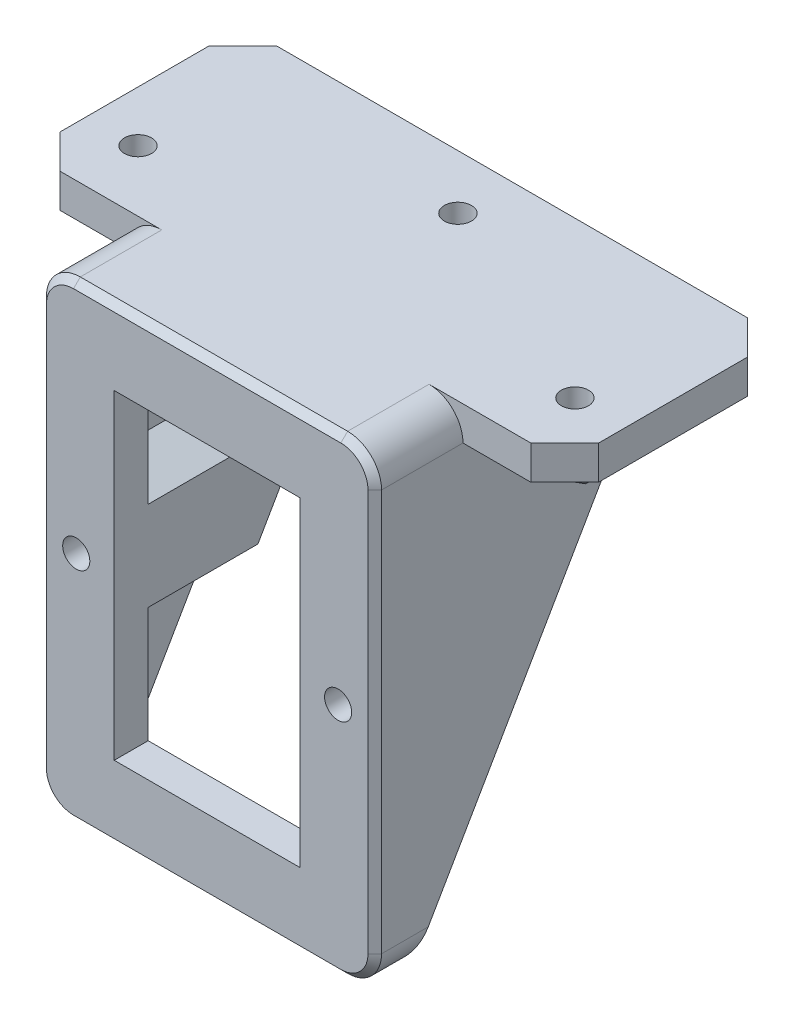
from build123d import *

# Parameters (mm, degrees)
SKETCH1_W           = 49.4
SKETCH1_H           = 69.2
SKETCH1_W_2         = 27.4
SKETCH1_H_2         = 47.2
BOSS_EXTRUDE1_DEPTH = 5
SKETCH2_R           = 2
CUT_EXTRUDE1_DEPTH  = 15
BOSS_EXTRUDE2_DEPTH = 49.4
CUT_EXTRUDE2_DEPTH  = 40.952638628
SKETCH5_W           = 27.4
SKETCH5_H           = 47.2
CUT_EXTRUDE3_DEPTH  = 93
CUT_EXTRUDE4_START  = -5
CUT_EXTRUDE4_DEPTH  = 93
SKETCH7_W           = 79.4
SKETCH7_H           = 44.952638628
BOSS_EXTRUDE3_DEPTH = 5
BOSS_EXTRUDE4_DEPTH = 3
CUT_EXTRUDE5_DEPTH  = 1
SKETCH10_R          = 2
CUT_EXTRUDE6_DEPTH  = 5
SKETCH11_W          = 15
SKETCH11_H          = 5
CUT_EXTRUDE7_DEPTH  = 13
CHAMFER1_SIZE       = 2.75
BOSS_EXTRUDE5_DEPTH = 0.5
CHAMFER2_SIZE       = 0.25
FILLET1_R           = 5
CHAMFER3_SIZE       = 1
CHAMFER4_SIZE       = 5


with BuildPart() as part:
    # Sketch1 → Boss-Extrude1 (new body)
    with BuildSketch(Plane.XY):
        Rectangle(SKETCH1_W, SKETCH1_H)
        Rectangle(SKETCH1_W_2, SKETCH1_H_2, mode=Mode.SUBTRACT)
    extrude(amount=-BOSS_EXTRUDE1_DEPTH)

    # Sketch2 → Cut-Extrude1 (cut)
    with BuildSketch(Plane.XY):
        with Locations((19.3, 0)):
            Circle(SKETCH2_R)
        with Locations((-19.3, 0)):
            Circle(SKETCH2_R)
    extrude(amount=-CUT_EXTRUDE1_DEPTH, mode=Mode.SUBTRACT)

    # Sketch4 → Boss-Extrude2 (add)
    with BuildSketch(Plane(origin=(24.7, 0, 0), x_dir=(0, 0, -1), z_dir=(1, 0, 0))):
        Polygon((5, 34.6), (44.952638628, 34.6), (5, -34.6), align=None)
    extrude(amount=-BOSS_EXTRUDE2_DEPTH)

    # Sketch3 → Cut-Extrude2 (cut, through all)
    with BuildSketch(Plane(origin=(0, 0, -5), x_dir=(-1, 0, 0), z_dir=(0, 0, -1))):
        Polygon((-19.3, -4.041451884), (-15.8, -2.020725942), (-15.8, 2.020725942), (-19.3, 4.041451884), (-22.8, 2.020725942), (-22.8, -2.020725942), align=None)
        Polygon((19.3, -4.041451884), (22.8, -2.020725942), (22.8, 2.020725942), (19.3, 4.041451884), (15.8, 2.020725942), (15.8, -2.020725942), align=None)
    extrude(amount=CUT_EXTRUDE2_DEPTH, mode=Mode.SUBTRACT)

    # Sketch5 → Cut-Extrude3 (cut)
    with BuildSketch(Plane.XY.offset(-5)):
        Rectangle(SKETCH5_W, SKETCH5_H)
    extrude(amount=-CUT_EXTRUDE3_DEPTH, mode=Mode.SUBTRACT)

    # Sketch6 → Cut-Extrude4 (cut)
    with BuildSketch(Plane.XY.offset(CUT_EXTRUDE4_START)):
        Polygon((19.7, 29.6), (-19.7, 29.6), (-19.7, 10.045894684), (-10.8, 4.907477288), (-10.8, -4.907477288), (-19.7, -10.045894684), (-19.7, -34.6), (19.7, -34.6), (19.7, -10.045894684), (10.8, -4.907477288), (10.8, 4.907477288), (19.7, 10.045894684), align=None)
    extrude(amount=-CUT_EXTRUDE4_DEPTH, mode=Mode.SUBTRACT)

    # Sketch7 → Boss-Extrude3 (add)
    with BuildSketch(Plane(origin=(0, 34.6, 0), x_dir=(1, 0, 0), z_dir=(0, 1, 0))):
        with Locations((0, 22.476319314)):
            Rectangle(SKETCH7_W, SKETCH7_H)
    extrude(amount=-BOSS_EXTRUDE3_DEPTH)

    # Sketch8 → Boss-Extrude4 (add)
    with BuildSketch(Plane.XZ.offset(-29.6)):
        Polygon((25.7, -25.75277675), (32.2, -29.505553499), (38.7, -25.75277675), (38.7, -18.24722325), (32.2, -14.494446501), (25.7, -18.24722325), align=None)
        Polygon((32.2, -17.958548116), (28.7, -19.979274058), (28.7, -24.020725942), (32.2, -26.041451884), (35.7, -24.020725942), (35.7, -19.979274058), align=None, mode=Mode.SUBTRACT)
        Polygon((-32.2, -14.494446501), (-38.7, -18.24722325), (-38.7, -25.75277675), (-32.2, -29.505553499), (-25.7, -25.75277675), (-25.7, -18.24722325), align=None)
        Polygon((-32.2, -17.958548116), (-35.7, -19.979274058), (-35.7, -24.020725942), (-32.2, -26.041451884), (-28.7, -24.020725942), (-28.7, -19.979274058), align=None, mode=Mode.SUBTRACT)
        Polygon((0, -29.447085128), (-6.5, -33.199861878), (-6.5, -40.705415378), (0, -44.458192127), (6.5, -40.705415378), (6.5, -33.199861878), align=None)
        Polygon((-3.5, -34.931912686), (-3.5, -38.97336457), (0, -40.994090512), (3.5, -38.97336457), (3.5, -34.931912686), (0, -32.911186744), align=None, mode=Mode.SUBTRACT)
    extrude(amount=BOSS_EXTRUDE4_DEPTH)

    # Sketch9 → Cut-Extrude5 (cut)
    with BuildSketch(Plane.XZ.offset(-29.6)):
        Polygon((35.7, -24.020725942), (35.7, -19.979274058), (32.2, -17.958548116), (28.7, -19.979274058), (28.7, -24.020725942), (32.2, -26.041451884), align=None)
        Polygon((3.5, -34.931912686), (0, -32.911186744), (-3.5, -34.931912686), (-3.5, -38.97336457), (0, -40.994090512), (3.5, -38.97336457), align=None)
        Polygon((-28.7, -24.020725942), (-28.7, -19.979274058), (-32.2, -17.958548116), (-35.7, -19.979274058), (-35.7, -24.020725942), (-32.2, -26.041451884), align=None)
    extrude(amount=-CUT_EXTRUDE5_DEPTH, mode=Mode.SUBTRACT)

    # Sketch10 → Cut-Extrude6 (cut, through all)
    with BuildSketch(Plane.XZ.offset(-30.6)):
        with Locations((32.2, -22)):
            Circle(SKETCH10_R)
        with Locations((0, -36.952638628)):
            Circle(SKETCH10_R)
        with Locations((-32.2, -22)):
            Circle(SKETCH10_R)
    extrude(amount=-CUT_EXTRUDE6_DEPTH, mode=Mode.SUBTRACT)

    # Sketch11 → Cut-Extrude7 (cut)
    with BuildSketch(Plane.XY):
        with Locations((32.2, 32.1)):
            Rectangle(SKETCH11_W, SKETCH11_H)
        with Locations((-32.2, 32.1)):
            Rectangle(SKETCH11_W, SKETCH11_H)
    extrude(amount=-CUT_EXTRUDE7_DEPTH, mode=Mode.SUBTRACT)

    # Chamfer1
    chamfer1_edges = [part.edges().sort_by_distance(p)[0] for p in [
        (25.7, 26.6, -22),
        (28.95, 26.6, -27.629165125),
        (35.45, 26.6, -27.629165125),
        (38.7, 26.6, -22),
        (35.45, 26.6, -16.370834875),
        (28.95, 26.6, -16.370834875),
        (-28.95, 26.6, -16.370834875),
        (-35.45, 26.6, -16.370834875),
        (-38.7, 26.6, -22),
        (-35.45, 26.6, -27.629165125),
        (-28.95, 26.6, -27.629165125),
        (-25.7, 26.6, -22),
        (3.25, 26.6, -31.323473503),
        (-3.25, 26.6, -31.323473503),
        (-6.5, 26.6, -36.952638628),
        (-3.25, 26.6, -42.581803753),
        (3.25, 26.6, -42.581803753),
        (6.5, 26.6, -36.952638628),
    ]]
    chamfer(chamfer1_edges, length=CHAMFER1_SIZE)

    # Sketch12 → Boss-Extrude5 (add)
    with BuildSketch(Plane.XZ.offset(-26.6)):
        Polygon((32.2, -26.041451884), (35.7, -24.020725942), (35.7, -19.979274058), (32.2, -17.958548116), (28.7, -19.979274058), (28.7, -24.020725942), align=None)
        Polygon((35.45, -20.123611625), (32.2, -18.24722325), (28.95, -20.123611625), (28.95, -23.876388375), (32.2, -25.75277675), (35.45, -23.876388375), align=None, mode=Mode.SUBTRACT)
        Polygon((3.5, -38.97336457), (3.5, -34.931912686), (0, -32.911186744), (-3.5, -34.931912686), (-3.5, -38.97336457), (0, -40.994090512), align=None)
        Polygon((-3.25, -38.829027003), (0, -40.705415378), (3.25, -38.829027003), (3.25, -35.076250253), (0, -33.199861878), (-3.25, -35.076250253), align=None, mode=Mode.SUBTRACT)
        Polygon((-32.2, -26.041451884), (-28.7, -24.020725942), (-28.7, -19.979274058), (-32.2, -17.958548116), (-35.7, -19.979274058), (-35.7, -24.020725942), align=None)
        Polygon((-35.45, -23.876388375), (-32.2, -25.75277675), (-28.95, -23.876388375), (-28.95, -20.123611625), (-32.2, -18.24722325), (-35.45, -20.123611625), align=None, mode=Mode.SUBTRACT)
    extrude(amount=-BOSS_EXTRUDE5_DEPTH)

    # Chamfer2
    chamfer2_edges = [part.edges().sort_by_distance(p)[0] for p in [
        (35.45, 26.6, -22),
        (33.825, 26.6, -24.814582562),
        (30.575, 26.6, -24.814582562),
        (28.95, 26.6, -22),
        (30.575, 26.6, -19.185417438),
        (33.825, 26.6, -19.185417438),
        (-3.25, 26.6, -36.952638628),
        (-1.625, 26.6, -34.138056066),
        (1.625, 26.6, -34.138056066),
        (3.25, 26.6, -36.952638628),
        (1.625, 26.6, -39.76722119),
        (-1.625, 26.6, -39.76722119),
        (-35.45, 26.6, -22),
        (-33.825, 26.6, -19.185417438),
        (-30.575, 26.6, -19.185417438),
        (-28.95, 26.6, -22),
        (-30.575, 26.6, -24.814582562),
        (-33.825, 26.6, -24.814582562),
    ]]
    chamfer(chamfer2_edges, length=CHAMFER2_SIZE)

    # Fillet1
    fillet1_edges = [part.edges().sort_by_distance(p)[0] for p in [
        (24.7, -34.6, -2.5),
        (-24.7, -34.6, -2.5),
        (-24.7, 34.6, -6.5),
        (24.7, 34.6, -6.5),
    ]]
    fillet(fillet1_edges, radius=FILLET1_R)

    # Chamfer3
    chamfer3_edges = [part.edges().sort_by_distance(p)[0] for p in [
        (0, -34.6, 0),
        (0, 34.6, 0),
        (-24.7, 0, 0),
        (24.7, 0, 0),
        (23.235533906, 33.135533906, 0),
        (-23.235533906, 33.135533906, 0),
        (-23.235533906, -33.135533906, 0),
        (23.235533906, -33.135533906, 0),
    ]]
    chamfer(chamfer3_edges, length=CHAMFER3_SIZE)

    # Chamfer4
    chamfer4_edges = [part.edges().sort_by_distance(p)[0] for p in [
        (-39.7, 32.1, -44.952638628),
        (39.7, 32.1, -44.952638628),
        (39.7, 32.1, -13),
        (-39.7, 32.1, -13),
    ]]
    chamfer(chamfer4_edges, length=CHAMFER4_SIZE)


solid = part.part
